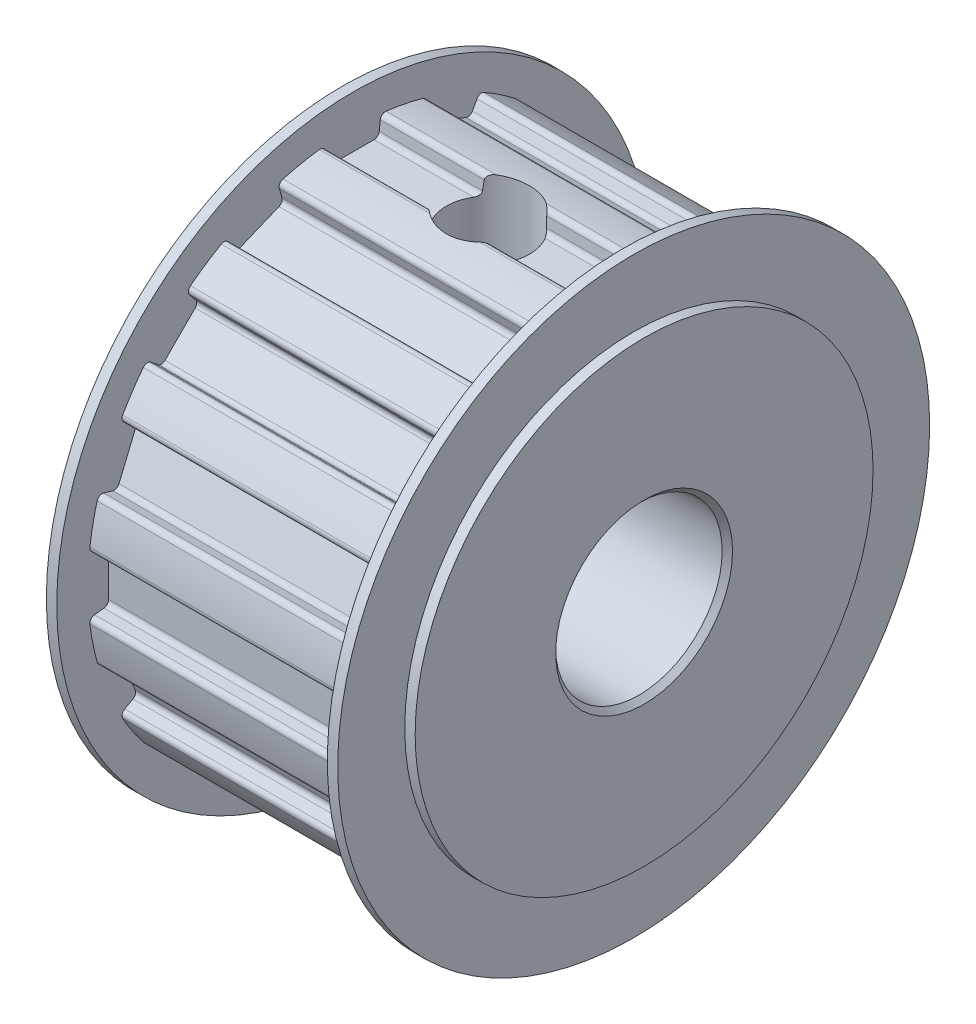
from build123d import *

# Parameters (mm, degrees)
ESQUISSE1_R                         = 12.73
EXTRUSION1_DEPTH                    = 13
ENL_V_MAT_EXTRU_2_DEPTH             = 13
CONG_1_R                            = 0.25
CONG_2_R                            = 0.25
CONG_3_R                            = 0.25
CONG_4_R                            = 0.25
R_P_TITION_CIRCULAIRE1_COUNT        = 16
CONG_1_OF_R_P_TITION_CIRCULAIRE1_R  = 0.25
CONG_2_OF_R_P_TITION_CIRCULAIRE1_R  = 0.25
CONG_3_OF_R_P_TITION_CIRCULAIRE1_R  = 0.25
CONG_4_OF_R_P_TITION_CIRCULAIRE1_R  = 0.25
ESQUISSE23_R                        = 14.22
EXTRUSION2_DEPTH                    = 1
ESQUISSE24_R                        = 14.22
EXTRUSION3_DEPTH                    = 1
ESQUISSE25_R                        = 4
ENL_V_MAT_EXTRU_3_DEPTH             = 16
ENL_V_MAT_EXTRU_5_REACH             = 27.95
ESQUISSE30_R                        = 2
ENL_V_MAT_EXTRU_5_DIRECTION_2_DEPTH = 3.49
ESQUISSE31_OUTSIDE_W                = 39.026
ESQUISSE31_OUTSIDE_H                = 39.026
ESQUISSE31_OUTSIDE_R                = 11
ENL_V_MAT_EXTRU_6_DEPTH             = 0.5
ESQUISSE32_OUTSIDE_W                = 39.026
ESQUISSE32_OUTSIDE_H                = 39.026
ESQUISSE32_OUTSIDE_R                = 11
ENL_V_MAT_EXTRU_7_DEPTH             = 0.5
CHANFREIN1_SIZE                     = 0.25
CHANFREIN2_SIZE                     = 0.25


with BuildPart() as part:
    # Esquisse1 → Extrusion1 (new body)
    with BuildSketch(Plane(origin=(0, 0, 0), x_dir=(0, 0, -1), z_dir=(1, 0, 0))):
        Circle(ESQUISSE1_R)
    extrude(amount=EXTRUSION1_DEPTH)

    # Esquisse22 → Enlèv. mat.-Extru.2 (cut)
    with BuildSketch(Plane.ZY):
        Polygon((-1.25, 11.73), (1.25, 11.73), (2.697915475, 25.31723882), (-2.698567022, 25.323352933), align=None)
    enl_v_mat_extru_2 = extrude(amount=-ENL_V_MAT_EXTRU_2_DEPTH, mode=Mode.SUBTRACT)

    # Congé1
    cong_1_edges = [part.edges().sort_by_distance(p)[0] for p in [
        (6.5, 11.73, -1.25),
    ]]
    fillet(cong_1_edges, radius=CONG_1_R)

    # Congé2
    cong_2_edges = [part.edges().sort_by_distance(p)[0] for p in [
        (6.5, 12.658329134, -1.348926805),
    ]]
    fillet(cong_2_edges, radius=CONG_2_R)

    # Congé3
    cong_3_edges = [part.edges().sort_by_distance(p)[0] for p in [
        (6.5, 11.73, 1.25),
    ]]
    fillet(cong_3_edges, radius=CONG_3_R)

    # Congé4
    cong_4_edges = [part.edges().sort_by_distance(p)[0] for p in [
        (6.5, 12.658329134, 1.348926805),
    ]]
    fillet(cong_4_edges, radius=CONG_4_R)

    # Répétition circulaire1: Enlèv. mat.-Extru.2 ×16 about axis
    r_p_tition_circulaire1_axis = Axis((0, 0, 0), (1, 0, 0))
    for i in range(1, R_P_TITION_CIRCULAIRE1_COUNT):
        add(enl_v_mat_extru_2.rotate(r_p_tition_circulaire1_axis, i * 360 / R_P_TITION_CIRCULAIRE1_COUNT), mode=Mode.SUBTRACT)

    # Congé1 of Répétition circulaire1
    cong_1_of_r_p_tition_circulaire1_edges = [part.edges().sort_by_distance(p)[0] for p in [
        (6.5, 11.315461207, 3.334027246),
        (6.5, 9.17824602, 7.410479067),
        (6.5, 5.643726077, 10.358752626),
        (6.5, 1.25, 11.73),
        (6.5, -3.334027246, 11.315461207),
        (6.5, -7.410479067, 9.17824602),
        (6.5, -10.358752626, 5.643726077),
        (6.5, -11.73, 1.25),
        (6.5, -11.315461207, -3.334027246),
        (6.5, -9.17824602, -7.410479067),
        (6.5, -5.643726077, -10.358752626),
        (6.5, -1.25, -11.73),
        (6.5, 3.334027246, -11.315461207),
        (6.5, 7.410479067, -9.17824602),
        (6.5, 10.358752626, -5.643726077),
    ]]
    fillet(cong_1_of_r_p_tition_circulaire1_edges, radius=CONG_1_OF_R_P_TITION_CIRCULAIRE1_R)

    # Congé2 of Répétition circulaire1
    cong_2_of_r_p_tition_circulaire1_edges = [part.edges().sort_by_distance(p)[0] for p in [
        (6.5, 12.210983143, 3.597886976),
        (6.5, 9.90462566, 7.996955079),
        (6.5, 6.090378707, 11.178559264),
        (6.5, 1.348926805, 12.658329134),
        (6.5, -3.597886976, 12.210983143),
        (6.5, -7.996955079, 9.90462566),
        (6.5, -11.178559264, 6.090378707),
        (6.5, -12.658329134, 1.348926805),
        (6.5, -12.210983143, -3.597886976),
        (6.5, -9.90462566, -7.996955079),
        (6.5, -6.090378707, -11.178559264),
        (6.5, -1.348926805, -12.658329134),
        (6.5, 3.597886976, -12.210983143),
        (6.5, 7.996955079, -9.90462566),
        (6.5, 11.178559264, -6.090378707),
    ]]
    fillet(cong_2_of_r_p_tition_circulaire1_edges, radius=CONG_2_OF_R_P_TITION_CIRCULAIRE1_R)

    # Congé3 of Répétition circulaire1
    cong_3_of_r_p_tition_circulaire1_edges = [part.edges().sort_by_distance(p)[0] for p in [
        (6.5, 10.358752626, 5.643726077),
        (6.5, 7.410479067, 9.17824602),
        (6.5, 3.334027246, 11.315461207),
        (6.5, -1.25, 11.73),
        (6.5, -5.643726077, 10.358752626),
        (6.5, -9.17824602, 7.410479067),
        (6.5, -11.315461207, 3.334027246),
        (6.5, -11.73, -1.25),
        (6.5, -10.358752626, -5.643726077),
        (6.5, -7.410479067, -9.17824602),
        (6.5, -3.334027246, -11.315461207),
        (6.5, 1.25, -11.73),
        (6.5, 5.643726077, -10.358752626),
        (6.5, 9.17824602, -7.410479067),
        (6.5, 11.315461207, -3.334027246),
    ]]
    fillet(cong_3_of_r_p_tition_circulaire1_edges, radius=CONG_3_OF_R_P_TITION_CIRCULAIRE1_R)

    # Congé4 of Répétition circulaire1
    cong_4_of_r_p_tition_circulaire1_edges = [part.edges().sort_by_distance(p)[0] for p in [
        (6.5, 11.178559264, 6.090378707),
        (6.5, 7.996955079, 9.90462566),
        (6.5, 3.597886976, 12.210983143),
        (6.5, -1.348926805, 12.658329134),
        (6.5, -6.090378707, 11.178559264),
        (6.5, -9.90462566, 7.996955079),
        (6.5, -12.210983143, 3.597886976),
        (6.5, -12.658329134, -1.348926805),
        (6.5, -11.178559264, -6.090378707),
        (6.5, -7.996955079, -9.90462566),
        (6.5, -3.597886976, -12.210983143),
        (6.5, 1.348926805, -12.658329134),
        (6.5, 6.090378707, -11.178559264),
        (6.5, 9.90462566, -7.996955079),
        (6.5, 12.210983143, -3.597886976),
    ]]
    fillet(cong_4_of_r_p_tition_circulaire1_edges, radius=CONG_4_OF_R_P_TITION_CIRCULAIRE1_R)

    # Esquisse23 → Extrusion2 (add)
    with BuildSketch(Plane.ZY):
        Circle(ESQUISSE23_R)
    extrude(amount=EXTRUSION2_DEPTH)

    # Esquisse24 → Extrusion3 (add)
    with BuildSketch(Plane(origin=(13, 0, 0), x_dir=(0, 0, -1), z_dir=(1, 0, 0))):
        Circle(ESQUISSE24_R)
    extrude(amount=EXTRUSION3_DEPTH)

    # Esquisse25 → Enlèv. mat.-Extru.3 (cut, through all)
    with BuildSketch(Plane.ZY.offset(1)):
        Circle(ESQUISSE25_R)
    extrude(amount=-ENL_V_MAT_EXTRU_3_DEPTH, mode=Mode.SUBTRACT)

    # Esquisse30 → Enlèv. mat.-Extru.5 (cut, up to next)
    with BuildSketch(Plane(origin=(0, 11.73, 0), x_dir=(-1, 0, 0), z_dir=(0, 1, 0)), mode=Mode.PRIVATE) as enl_v_mat_extru_5_sk1:
        with Locations((-6.5, 0)):
            Circle(ESQUISSE30_R)
    enl_v_mat_extru_5_tool1 = extrude(enl_v_mat_extru_5_sk1.sketch, amount=-ENL_V_MAT_EXTRU_5_REACH, mode=Mode.PRIVATE) & part.part
    add(enl_v_mat_extru_5_tool1.solids().sort_by_distance((6.5, 11.73, 0))[0], mode=Mode.SUBTRACT)

    # Esquisse30 → Enlèv. mat.-Extru.5 direction 2 (cut)
    with BuildSketch(Plane(origin=(0, 11.73, 0), x_dir=(-1, 0, 0), z_dir=(0, 1, 0))):
        with Locations((-6.5, 0)):
            Circle(ESQUISSE30_R)
    extrude(amount=ENL_V_MAT_EXTRU_5_DIRECTION_2_DEPTH, mode=Mode.SUBTRACT)

    # Esquisse31 outside → Enlèv. mat.-Extru.6 (cut)
    with BuildSketch(Plane.ZY.offset(1)):
        Rectangle(ESQUISSE31_OUTSIDE_W, ESQUISSE31_OUTSIDE_H)
        Circle(ESQUISSE31_OUTSIDE_R, mode=Mode.SUBTRACT)
    extrude(amount=-ENL_V_MAT_EXTRU_6_DEPTH, mode=Mode.SUBTRACT)

    # Esquisse32 outside → Enlèv. mat.-Extru.7 (cut)
    with BuildSketch(Plane(origin=(14, 0, 0), x_dir=(0, 0, -1), z_dir=(1, 0, 0))):
        Rectangle(ESQUISSE32_OUTSIDE_W, ESQUISSE32_OUTSIDE_H)
        Circle(ESQUISSE32_OUTSIDE_R, mode=Mode.SUBTRACT)
    extrude(amount=-ENL_V_MAT_EXTRU_7_DEPTH, mode=Mode.SUBTRACT)

    # Chanfrein1
    chanfrein1_edges = [part.edges().sort_by_distance(p)[0] for p in [
        (14, 0, -4),
    ]]
    chamfer(chanfrein1_edges, length=CHANFREIN1_SIZE)

    # Chanfrein2
    chanfrein2_edges = [part.edges().sort_by_distance(p)[0] for p in [
        (-1, 0, -4),
    ]]
    chamfer(chanfrein2_edges, length=CHANFREIN2_SIZE)


solid = part.part
